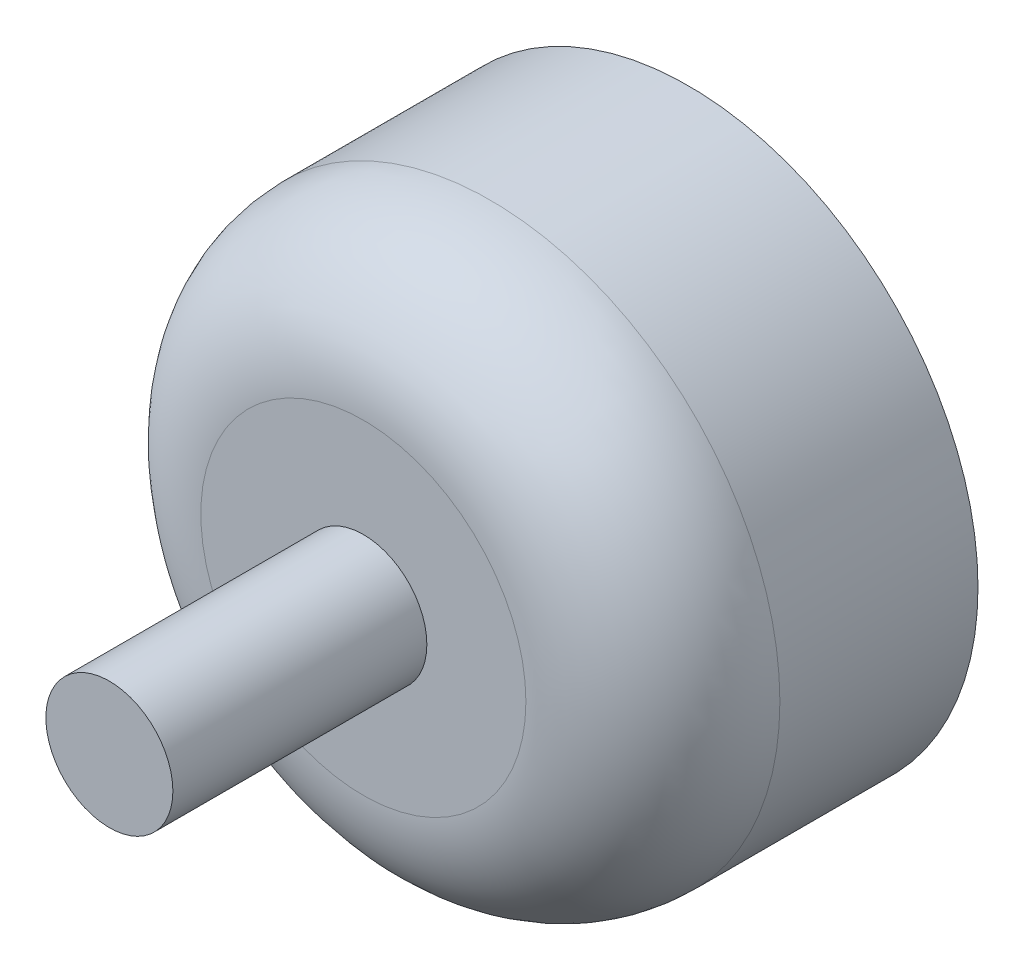
from build123d import *

# Parameters (mm, degrees)
SKETCH_1_R               = 11.4
EXTRUDE_1_DEPTH          = 12.8
SKETCH_2_R               = 1
CUT_EXTRUDE_1_DEPTH      = 3
PATTERN_CIRCULAR_1_COUNT = 4
SKETCH_3_R               = 3
EXTRUDE_2_DEPTH          = 0.5
SKETCH_4_R               = 1.5
EXTRUDE_3_DEPTH          = 1
SKETCH_5_R               = 2.5
EXTRUDE_4_DEPTH          = 10
FILLET_1_R               = 5


with BuildPart() as part:
    # 草图1 → 凸台-拉伸1 (new body)
    with BuildSketch(Plane.XY):
        Circle(SKETCH_1_R)
    extrude(amount=EXTRUDE_1_DEPTH)

    # 草图2 → 切除-拉伸1 (cut)
    with BuildSketch(Plane(origin=(0, 0, 0), x_dir=(-1, 0, 0), z_dir=(0, 0, -1))):
        with Locations((6, 0)):
            Circle(SKETCH_2_R)
    cut_extrude_1 = extrude(amount=-CUT_EXTRUDE_1_DEPTH, mode=Mode.SUBTRACT)

    # 阵列(圆周)1: 切除-拉伸1 ×4 about axis
    pattern_circular_1_axis = Axis((0, 0, 13.44), (0, 0, -1))
    for i in range(1, PATTERN_CIRCULAR_1_COUNT):
        add(cut_extrude_1.rotate(pattern_circular_1_axis, i * 360 / PATTERN_CIRCULAR_1_COUNT), mode=Mode.SUBTRACT)

    # 草图3 → 凸台-拉伸2 (add)
    with BuildSketch(Plane(origin=(0, 0, 0), x_dir=(-1, 0, 0), z_dir=(0, 0, -1))):
        Circle(SKETCH_3_R)
    extrude(amount=EXTRUDE_2_DEPTH)

    # 草图4 → 凸台-拉伸3 (add)
    with BuildSketch(Plane(origin=(0, 0, -0.5), x_dir=(-1, 0, 0), z_dir=(0, 0, -1))):
        Circle(SKETCH_4_R)
    extrude(amount=EXTRUDE_3_DEPTH)

    # 草图5 → 凸台-拉伸4 (add)
    with BuildSketch(Plane.XY.offset(12.8)):
        Circle(SKETCH_5_R)
    extrude(amount=EXTRUDE_4_DEPTH)

    # 圆角1
    fillet_1_edges = [part.edges().sort_by_distance(p)[0] for p in [
        (-11.4, 0, 12.8),
    ]]
    fillet(fillet_1_edges, radius=FILLET_1_R)


solid = part.part
